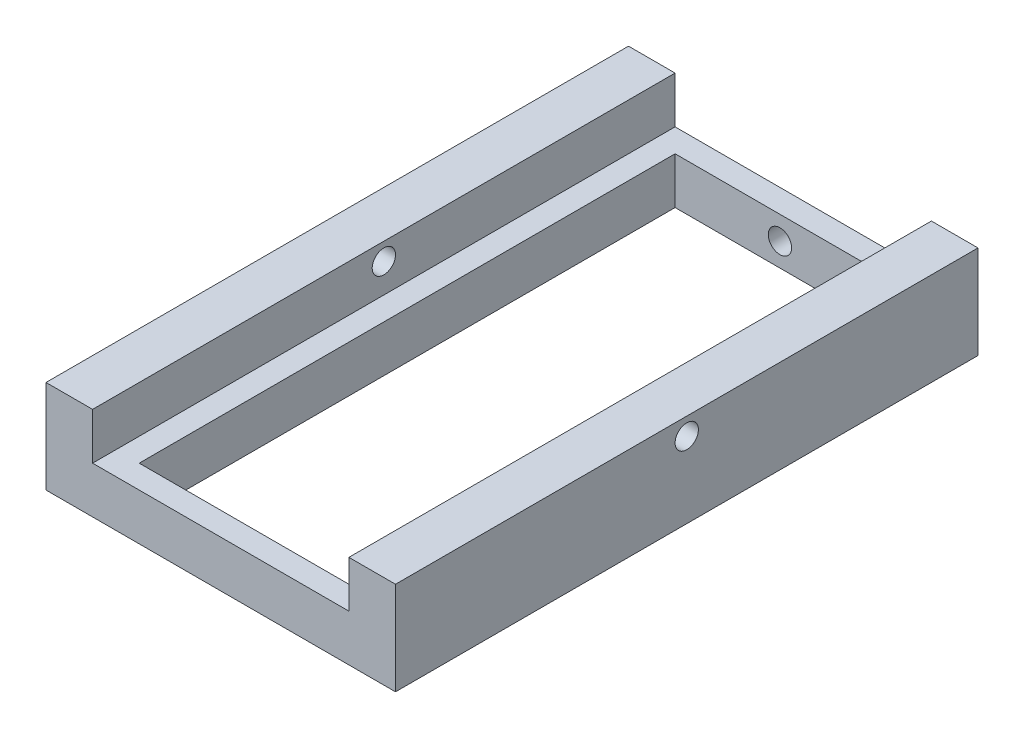
from build123d import *

# Parameters (mm, degrees)
BOSS_EXTRUDE1_DEPTH = 250
SKETCH2_W           = 180
SKETCH2_H           = 460
CUT_EXTRUDE1_DEPTH  = 41
SKETCH5_R           = 10
CUT_EXTRUDE5_DEPTH  = 15
SKETCH6_R           = 10
CUT_EXTRUDE6_DEPTH  = 20
SKETCH7_R           = 10
CUT_EXTRUDE7_DEPTH  = 300


with BuildPart() as part:
    # Sketch1 → Boss-Extrude1 (new body, symmetric)
    with BuildSketch(Plane.XY):
        Polygon((-110, 10), (110, 10), (110, 50), (150, 50), (150, 10), (150, -30), (-150, -30), (-150, 10), (-150, 50), (-110, 50), align=None)
    extrude(amount=BOSS_EXTRUDE1_DEPTH, both=True)

    # Sketch2 → Cut-Extrude1 (cut, through all)
    with BuildSketch(Plane(origin=(0, 10, 0), x_dir=(1, 0, 0), z_dir=(0, 1, 0))):
        Rectangle(SKETCH2_W, SKETCH2_H)
    extrude(amount=-CUT_EXTRUDE1_DEPTH, mode=Mode.SUBTRACT)

    # Sketch5 → Cut-Extrude5 (cut)
    with BuildSketch(Plane(origin=(0, 0, 230), x_dir=(-1, 0, 0), z_dir=(0, 0, -1))):
        with Locations((0, -10)):
            Circle(SKETCH5_R)
    extrude(amount=-CUT_EXTRUDE5_DEPTH, mode=Mode.SUBTRACT)

    # Sketch6 → Cut-Extrude6 (cut)
    with BuildSketch(Plane(origin=(0, 0, -250), x_dir=(-1, 0, 0), z_dir=(0, 0, -1))):
        with Locations((0, -10)):
            Circle(SKETCH6_R)
    extrude(amount=-CUT_EXTRUDE6_DEPTH, mode=Mode.SUBTRACT)

    # Sketch7 → Cut-Extrude7 (cut)
    with BuildSketch(Plane.ZY.offset(150)):
        with Locations((0, 35)):
            Circle(SKETCH7_R)
    extrude(amount=-CUT_EXTRUDE7_DEPTH, mode=Mode.SUBTRACT)


solid = part.part
